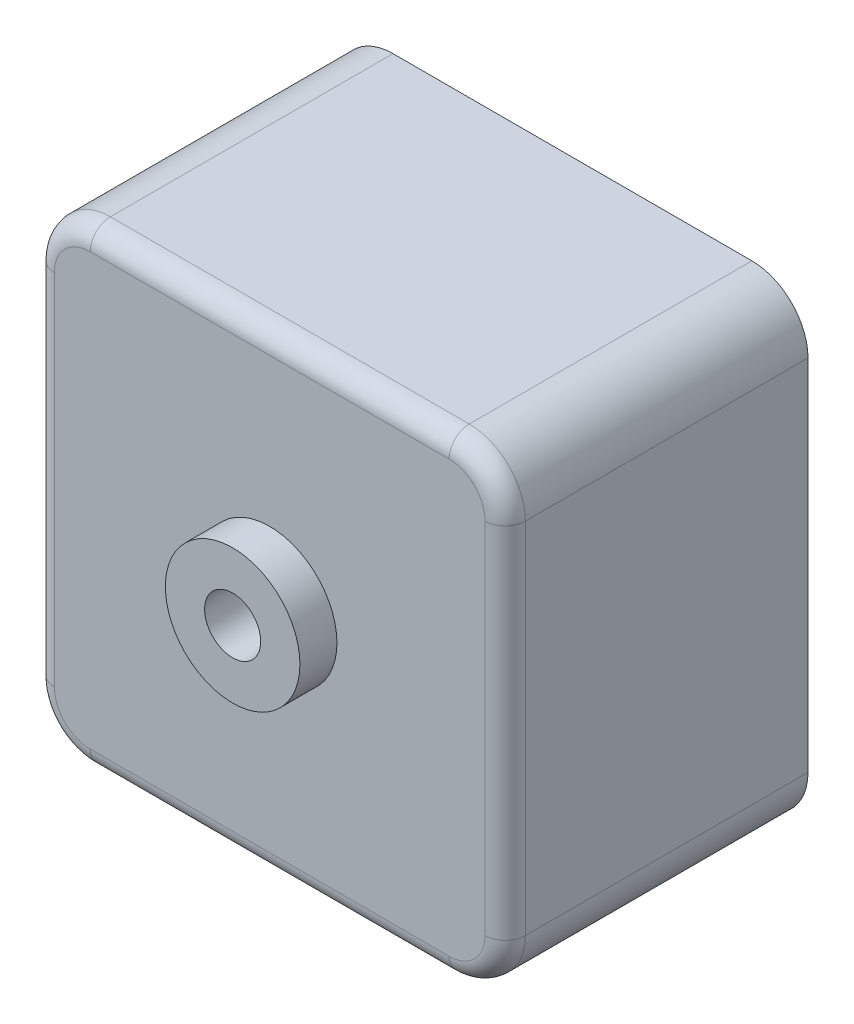
from build123d import *

# Parameters (mm, degrees)
CROQUIS1_W              = 42
CROQUIS1_H              = 42
SALIENTE_EXTRUIR1_DEPTH = 27
REDONDEO1_R             = 5
REDONDEO2_R             = 1.8
CROQUIS4_R              = 2.5
CORTAR_EXTRUIR1_DEPTH   = 38.8


with BuildPart() as part:
    # Croquis1 → Saliente-Extruir1 (new body)
    with BuildSketch(Plane.XY.offset(27)):
        with Locations((21, 21)):
            Rectangle(CROQUIS1_W, CROQUIS1_H)
    extrude(amount=-SALIENTE_EXTRUIR1_DEPTH)

    # Croquis2 → Revolución1 (revolve)
    with BuildSketch(Plane(origin=(0, 21, 0), x_dir=(1, 0, 0), z_dir=(0, 1, 0))):
        Polygon((27, -27), (21, -27), (21, -37.8), (23.5, -37.8), (23.5, -30.3), (27, -30.3), align=None)
    revolve(axis=Axis((21, 21, 27), (0, 0, 1)))

    # Redondeo1
    redondeo1_edges = [part.edges().sort_by_distance(p)[0] for p in [
        (42, 0, 13.5),
        (0, 0, 13.5),
        (0, 42, 13.5),
        (42, 42, 13.5),
    ]]
    fillet(redondeo1_edges, radius=REDONDEO1_R)

    # Redondeo2
    redondeo2_edges = [part.edges().sort_by_distance(p)[0] for p in [
        (21, 0, 27),
        (42, 21, 27),
        (21, 42, 27),
        (0, 21, 27),
        (40.535533906, 40.535533906, 27),
        (1.464466094, 1.464466094, 27),
        (1.464466094, 40.535533906, 27),
        (40.535533906, 1.464466094, 27),
    ]]
    fillet(redondeo2_edges, radius=REDONDEO2_R)

    # Croquis4 → Cortar-Extruir1 (cut, through all)
    with BuildSketch(Plane.XY.offset(37.8)):
        with Locations((21, 21)):
            Circle(CROQUIS4_R)
    extrude(amount=-CORTAR_EXTRUIR1_DEPTH, mode=Mode.SUBTRACT)


solid = part.part
